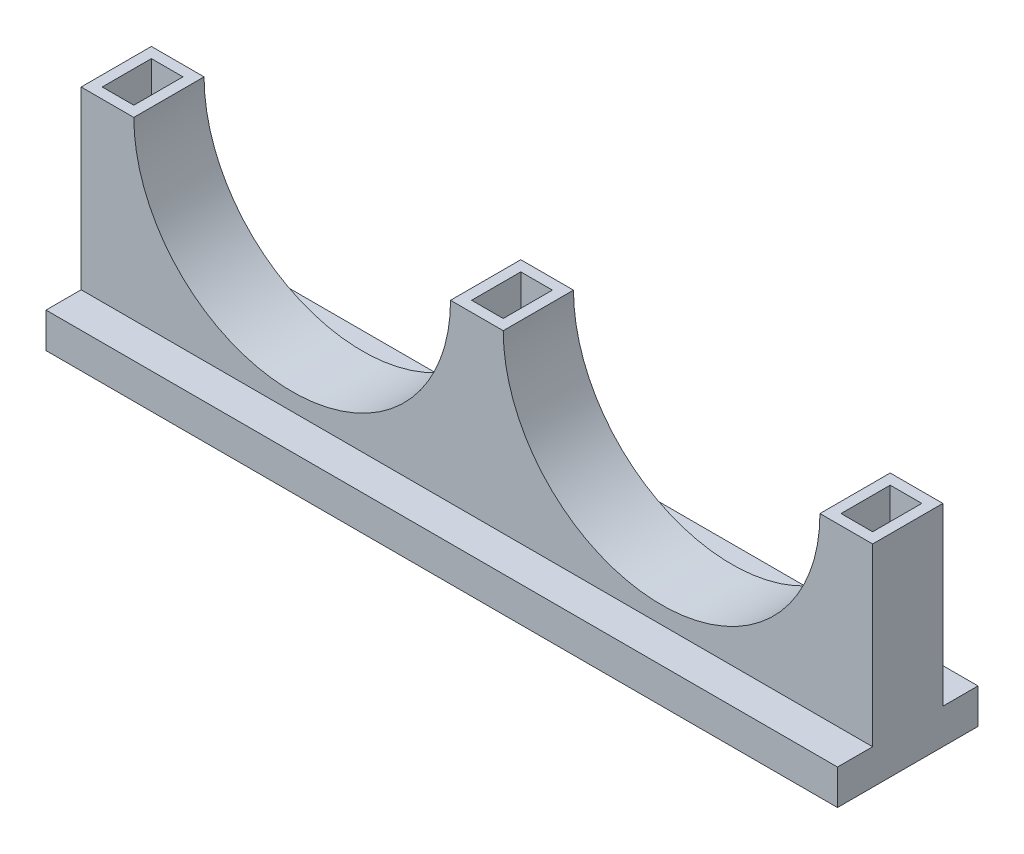
from build123d import *

# Parameters (mm, degrees)
BOSS_EXTRUDE2_DEPTH      = 20
SKETCH8_W                = 9
SKETCH8_H                = 14
CUT_EXTRUDE1_DEPTH       = 10
CUT_EXTRUDE1_TAPER       = 1
BOSS_EXTRUDE3_START      = -10
SKETCH9_W                = 225.34
SKETCH9_H                = 10
BOSS_EXTRUDE3_DEPTH      = 20
BOSS_EXTRUDE3_DEPTH_BACK = 20


with BuildPart() as part:
    # Sketch7 → Boss-Extrude2 (new body)
    with BuildSketch(Plane.XY):
        with BuildLine():
            Line((0, 10), (0, 60))
            Line((0, 60), (15, 60))
            ThreePointArc((15, 60), (60.085, 14.915), (105.17, 60))
            Line((105.17, 60), (120.17, 60))
            ThreePointArc((120.17, 60), (165.255, 14.915), (210.34, 60))
            Line((210.34, 60), (225.34, 60))
            Line((225.34, 60), (225.34, 0))
            Line((225.34, 0), (0, 0))
            Line((0, 0), (0, 10))
        make_face()
    extrude(amount=BOSS_EXTRUDE2_DEPTH)

    # Sketch8 → Cut-Extrude1 (cut)
    with BuildSketch(Plane(origin=(0, 60, 0), x_dir=(1, 0, 0), z_dir=(0, 1, 0))):
        with Locations((7.5, -10)):
            Rectangle(SKETCH8_W, SKETCH8_H)
        with Locations((217.84, -10)):
            Rectangle(SKETCH8_W, SKETCH8_H)
        with Locations((112.67, -10)):
            Rectangle(SKETCH8_W, SKETCH8_H)
    extrude(amount=-CUT_EXTRUDE1_DEPTH, taper=CUT_EXTRUDE1_TAPER, mode=Mode.SUBTRACT)

    # Sketch9 → Boss-Extrude3 (add, two sides)
    with BuildSketch(Plane.XY.offset(20).offset(BOSS_EXTRUDE3_START)) as boss_extrude3_sk:
        with Locations((112.67, 5)):
            Rectangle(SKETCH9_W, SKETCH9_H)
    extrude(amount=BOSS_EXTRUDE3_DEPTH)
    extrude(boss_extrude3_sk.sketch, amount=-BOSS_EXTRUDE3_DEPTH_BACK)


solid = part.part
